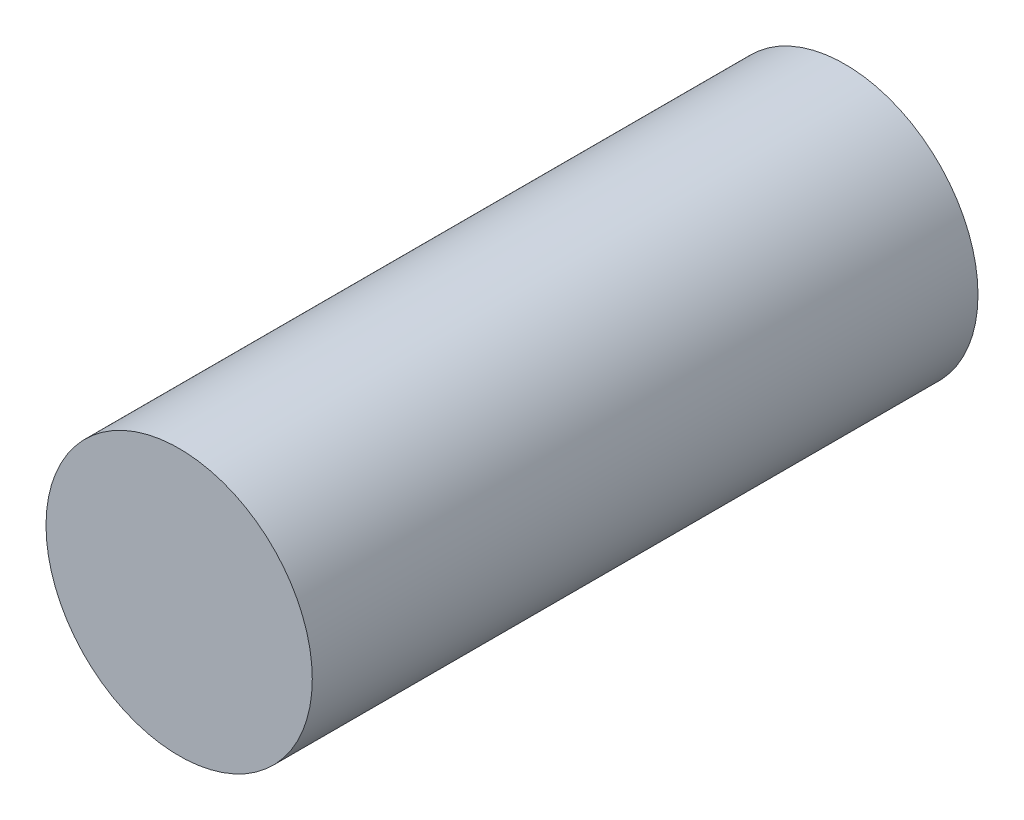
from build123d import *

# Parameters (mm, degrees)
SKETCH1_R           = 6
BOSS_EXTRUDE1_DEPTH = 30


with BuildPart() as part:
    # Sketch1 → Boss-Extrude1 (new body)
    with BuildSketch(Plane.XY):
        Circle(SKETCH1_R)
    extrude(amount=BOSS_EXTRUDE1_DEPTH)


solid = part.part
